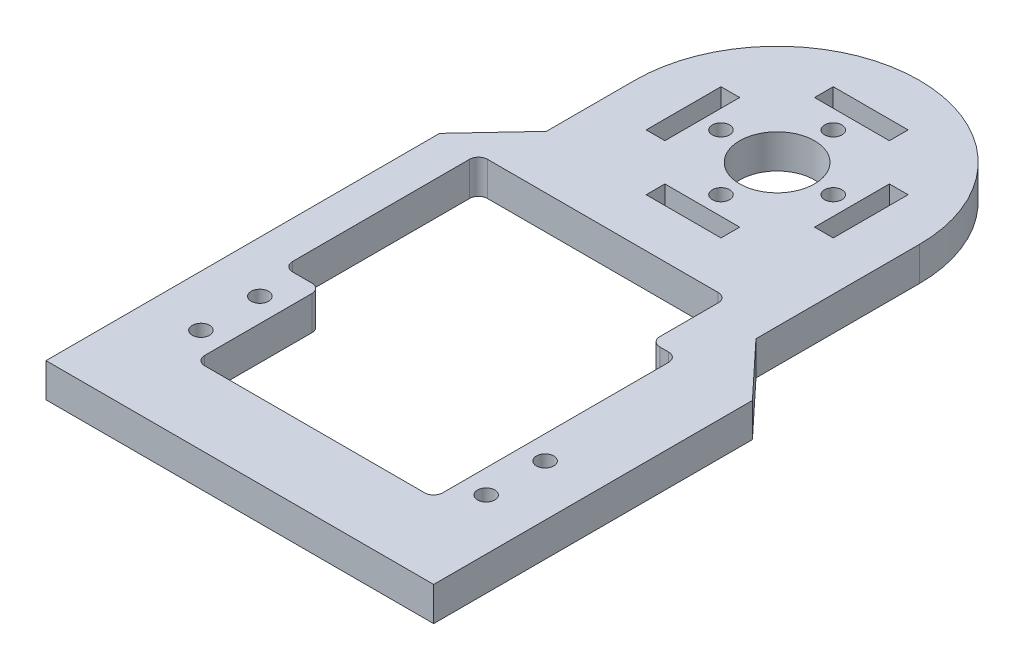
from build123d import *

# Parameters (mm, degrees)
SKETCH2_R                 = 24.13
SKETCH2_R_2               = 6.35
BOSS_EXTRUDE1_DEPTH       = 5.7658
SKETCH10_W                = 12.7
SKETCH10_H                = 3.175
CUT_EXTRUDE2_DEPTH        = 5.7658
F_4_CLEARANCE_HOLE2_D     = 2.9464
F_4_CLEARANCE_HOLE2_DEPTH = 5.7668
CIRPATTERN2_COUNT         = 4
BOSS_EXTRUDE2_DEPTH       = 5.7658
BOSS_EXTRUDE4_DEPTH       = 5.7658
F_4_CLEARANCE_HOLE3_D     = 2.9464
F_4_CLEARANCE_HOLE3_DEPTH = 5.7658
BOSS_EXTRUDE3_DEPTH       = 5.7658
CUT_EXTRUDE4_REACH        = 7.766
SKETCH30_W                = 10.8839
SKETCH30_H                = 33.094
FILLET2_R                 = 1.524


with BuildPart() as part:
    # Sketch2 → Boss-Extrude1 (new body)
    with BuildSketch(Plane(origin=(0, 0, 0), x_dir=(1, 0, 0), z_dir=(0, 1, 0))):
        Circle(SKETCH2_R)
        Circle(SKETCH2_R_2, mode=Mode.SUBTRACT)
    extrude(amount=BOSS_EXTRUDE1_DEPTH)

    # Sketch10 → Cut-Extrude2 (cut)
    with BuildSketch(Plane(origin=(0, 5.7658, 0), x_dir=(1, 0, 0), z_dir=(0, 1, 0))):
        with Locations((0, 14.2875)):
            Rectangle(SKETCH10_W, SKETCH10_H)
    cut_extrude2 = extrude(amount=-CUT_EXTRUDE2_DEPTH, mode=Mode.SUBTRACT)

    # #4 Clearance Hole2
    with Locations(Plane(origin=(0, 5.7658, 0), x_dir=(1, 0, 0), z_dir=(0, 1, 0))):
        with Locations((0, 9.525)):
            f_4_clearance_hole2 = Hole(F_4_CLEARANCE_HOLE2_D / 2, depth=F_4_CLEARANCE_HOLE2_DEPTH)

    # CirPattern2: Cut-Extrude2, #4 Clearance Hole2 ×4 about axis
    cirpattern2_axis = Axis((0, 0, 0), (0, 1, 0))
    for i in range(1, CIRPATTERN2_COUNT):
        add(cut_extrude2.rotate(cirpattern2_axis, i * 360 / CIRPATTERN2_COUNT), mode=Mode.SUBTRACT)
        add(f_4_clearance_hole2.rotate(cirpattern2_axis, i * 360 / CIRPATTERN2_COUNT), mode=Mode.SUBTRACT)

    # Sketch16 → Boss-Extrude2 (add)
    with BuildSketch(Plane(origin=(0, 5.7658, 0), x_dir=(1, 0, 0), z_dir=(0, 1, 0))):
        with BuildLine():
            Line((-24.13, 0), (-24.13, -27.721453785))
            Line((-24.13, -27.721453785), (-32.893, -37.084))
            Line((-32.893, -37.084), (-32.893, -91.174))
            Line((-32.893, -91.174), (32.893, -91.174))
            Line((32.893, -91.174), (32.893, -37.084))
            Line((32.893, -37.084), (24.13, -27.721453785))
            Line((24.13, -27.721453785), (24.13, 0))
            ThreePointArc((24.13, 0), (21.910168678, -10.109471228), (15.6591, -18.358907571))
            Line((15.6591, -18.358907571), (15.6591, -37.084))
            Line((15.6591, -37.084), (20.193, -37.084))
            Line((20.193, -37.084), (20.193, -58.674))
            Line((20.193, -58.674), (20.193, -78.474))
            Line((20.193, -78.474), (-20.193, -78.474))
            Line((-20.193, -78.474), (-20.193, -58.674))
            Line((-20.193, -58.674), (-20.193, -37.084))
            Line((-20.193, -37.084), (-15.6591, -37.084))
            Line((-15.6591, -37.084), (-15.6591, -18.358907571))
            ThreePointArc((-15.6591, -18.358907571), (-21.910168678, -10.109471228), (-24.13, 0))
        make_face()
    extrude(amount=-BOSS_EXTRUDE2_DEPTH)

    # Sketch32 → Boss-Extrude4 (add)
    with BuildSketch(Plane(origin=(0, 5.7658, 0), x_dir=(1, 0, 0), z_dir=(0, 1, 0))):
        with BuildLine():
            ThreePointArc((15.6591, -18.358907571), (8.344353159, -22.64130452), (-6.7e-08, -24.13))
            Line((-6.7e-08, -24.13), (15.6591, -24.13))
            Line((15.6591, -24.13), (15.6591, -18.358907571))
        make_face()
        with BuildLine():
            Line((-15.6591, -18.358907571), (-15.6591, -24.13))
            Line((-15.6591, -24.13), (-6.7e-08, -24.13))
            ThreePointArc((-6.7e-08, -24.13), (-8.344353221, -22.641304497), (-15.6591, -18.358907571))
        make_face()
    extrude(amount=-BOSS_EXTRUDE4_DEPTH)

    # #4 Clearance Hole3
    with Locations(Plane(origin=(0, 5.7658, 0), x_dir=(1, 0, 0), z_dir=(0, 1, 0))):
        with Locations((-24.2, -63.574), (-24.2, -73.574), (24.2, -63.574), (24.2, -73.574)):
            Hole(F_4_CLEARANCE_HOLE3_D / 2, depth=F_4_CLEARANCE_HOLE3_DEPTH)

    # Sketch31 → Boss-Extrude3 (add)
    with BuildSketch(Plane(origin=(0, 5.7658, 0), x_dir=(1, 0, 0), z_dir=(0, 1, 0))):
        Polygon((-32.893, -37.084), (-32.893, -24.384), (-24.13, -15.021453785), (-24.13, -27.721453785), align=None)
    extrude(amount=-BOSS_EXTRUDE3_DEPTH)

    # Sketch30 → Cut-Extrude4 (cut, up to next)
    with BuildSketch(Plane(origin=(0, 5.7658, 0), x_dir=(1, 0, 0), z_dir=(0, 1, 0)), mode=Mode.PRIVATE) as cut_extrude4_sk1:
        with Locations((-21.10105, -40.677)):
            Rectangle(SKETCH30_W, SKETCH30_H)
    cut_extrude4_tool1 = extrude(cut_extrude4_sk1.sketch, amount=-CUT_EXTRUDE4_REACH, mode=Mode.PRIVATE) & part.part
    add(cut_extrude4_tool1.solids().sort_by_distance((-21.10105, 5.7658, 40.677))[0], mode=Mode.SUBTRACT)

    # Fillet2
    fillet2_edges = [part.edges().sort_by_distance(p)[0] for p in [
        (15.6591, 2.8829, 24.13),
        (-26.543, 2.8829, 57.224),
        (-26.543, 2.8829, 24.13),
        (-20.193, 2.8829, 57.224),
        (-20.193, 2.8829, 78.474),
        (20.193, 2.8829, 78.474),
        (20.193, 2.8829, 37.084),
        (15.6591, 2.8829, 37.084),
    ]]
    fillet(fillet2_edges, radius=FILLET2_R)


solid = part.part
